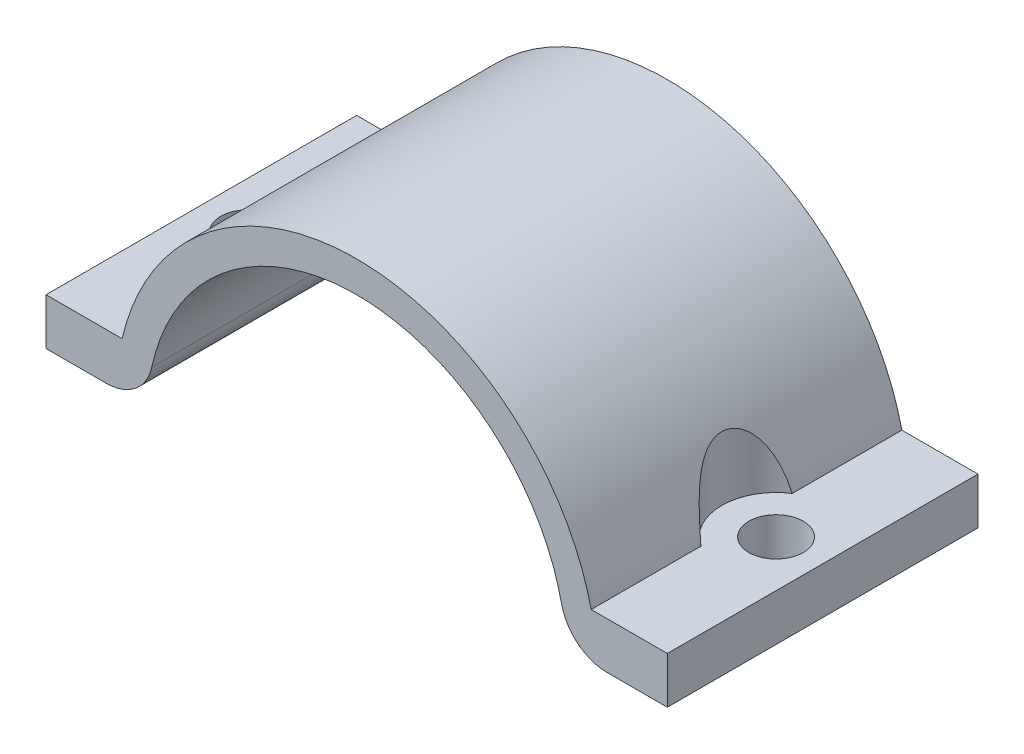
from build123d import *

# Parameters (mm, degrees)
BOSS_EXTRU_2_DEPTH      = 20
ESQUISSE3_R             = 1.75
ENL_V_MAT_EXTRU_2_DEPTH = 4
ESQUISSE4_R             = 3.5
ENL_V_MAT_EXTRU_3_DEPTH = 13


with BuildPart() as part:
    # Esquisse1 → Boss.-Extru.2 (new body)
    with BuildSketch(Plane.XY):
        with BuildLine():
            Line((-20, 0.5), (-16.124515497, 0.5))
            ThreePointArc((-16.124515497, 0.5), (-14.241577753, 1.164503168), (-13.192785406, 2.863636364))
            ThreePointArc((-13.192785406, 2.863636364), (0, 13.5), (13.192785406, 2.863636364))
            ThreePointArc((13.192785406, 2.863636364), (14.241577753, 1.164503168), (16.124515497, 0.5))
            Line((16.124515497, 0.5), (20, 0.5))
            Line((20, 0.5), (20, 3.5))
            Line((20, 3.5), (15.099668871, 3.5))
            ThreePointArc((15.099668871, 3.5), (0, 15.5), (-15.099668871, 3.5))
            Line((-15.099668871, 3.5), (-20, 3.5))
            Line((-20, 3.5), (-20, 0.5))
        make_face()
    extrude(amount=BOSS_EXTRU_2_DEPTH)

    # Esquisse3 → Enlèv. mat.-Extru.2 (cut, through all)
    with BuildSketch(Plane(origin=(0, 3.5, 0), x_dir=(1, 0, 0), z_dir=(0, 1, 0))):
        with Locations((-17, -10)):
            Circle(ESQUISSE3_R)
        with Locations((17, -10)):
            Circle(ESQUISSE3_R)
    extrude(amount=-ENL_V_MAT_EXTRU_2_DEPTH, mode=Mode.SUBTRACT)

    # Esquisse4 → Enlèv. mat.-Extru.3 (cut, through all)
    with BuildSketch(Plane(origin=(0, 3.5, 0), x_dir=(1, 0, 0), z_dir=(0, 1, 0))):
        with Locations((-17, -10)):
            Circle(ESQUISSE4_R)
        with Locations((17, -10)):
            Circle(ESQUISSE4_R)
    extrude(amount=ENL_V_MAT_EXTRU_3_DEPTH, mode=Mode.SUBTRACT)


solid = part.part
